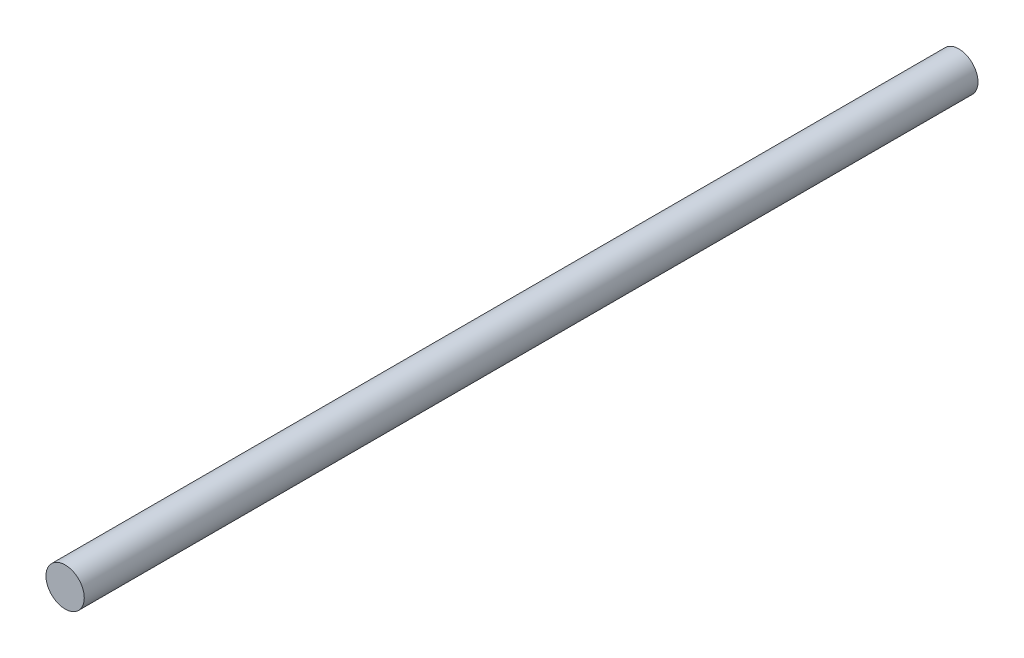
from build123d import *

# Parameters (mm, degrees)
SKETCH1_R           = 3
BOSS_EXTRUDE1_DEPTH = 140


with BuildPart() as part:
    # Sketch1 → Boss-Extrude1 (new body)
    with BuildSketch(Plane.XY):
        Circle(SKETCH1_R)
    extrude(amount=BOSS_EXTRUDE1_DEPTH)


solid = part.part
